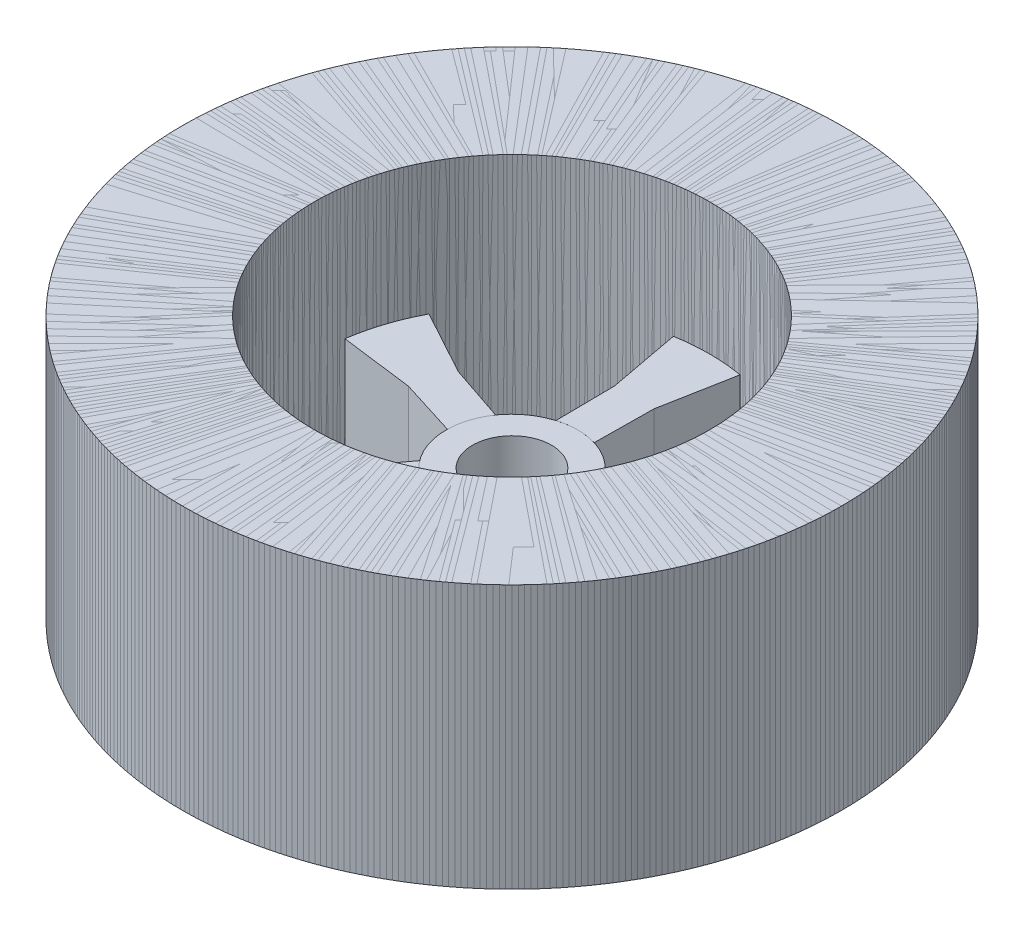
from build123d import *

# Parameters (mm, degrees)
SKETCH1_R           = 25
BOSS_EXTRUDE1_DEPTH = 20
BOSS_EXTRUDE3_DEPTH = 10
SKETCH1_3_R         = 3
BOSS_EXTRUDE2_DEPTH = 10
CIRPATTERN7_COUNT   = 5


with BuildPart() as part:
    # Sketch1 → Boss-Extrude1 (new body)
    with BuildSketch(Plane(origin=(0, 0, 0), x_dir=(1, 0, 0), z_dir=(0, 1, 0))):
        Circle(SKETCH1_R)
        with BuildLine():
            ThreePointArc((15, 0), (-9.670202954, -11.466785724), (-2.531623311, 14.784819357))
            ThreePointArc((-2.531623311, 14.784819357), (0, 15), (2.531623311, 14.784819357))
            ThreePointArc((2.531623311, 14.784819357), (11.466785724, 9.670202954), (15, 0))
        make_face(mode=Mode.SUBTRACT)
    extrude(amount=BOSS_EXTRUDE1_DEPTH)

    # Sketch1_4 → Boss-Extrude3 (add)
    with BuildSketch(Plane(origin=(0, 0, 0), x_dir=(1, 0, 0), z_dir=(0, 1, 0))):
        with BuildLine():
            ThreePointArc((2.531623311, 14.784819357), (0, 15), (-2.531623311, 14.784819357))
            Line((-2.531623311, 14.784819357), (-1.5, 9.284819357))
            Line((-1.5, 9.284819357), (-1.451035397, 4.784819357))
            ThreePointArc((-1.451035397, 4.784819357), (0, 5), (1.451035397, 4.784819357))
            Line((1.451035397, 4.784819357), (1.5, 9.284819357))
            Line((1.5, 9.284819357), (2.531623311, 14.784819357))
        make_face()
    extrude(amount=BOSS_EXTRUDE3_DEPTH)


with BuildPart() as body_2:
    # Sketch1_3 → Boss-Extrude2 (new body)
    with BuildSketch(Plane(origin=(0, 0, 0), x_dir=(1, 0, 0), z_dir=(0, 1, 0))):
        with BuildLine():
            ThreePointArc((1.451035397, 4.784819357), (0, 5), (-1.451035397, 4.784819357))
            ThreePointArc((-1.451035397, 4.784819357), (-2.978659347, -4.015916893), (5, 0))
            ThreePointArc((5, 0), (4.015916893, 2.978659347), (1.451035397, 4.784819357))
        make_face()
        Circle(SKETCH1_3_R, mode=Mode.SUBTRACT)
    extrude(amount=BOSS_EXTRUDE2_DEPTH)


with BuildPart() as cirpattern7_1:
    # CirPattern7: pattern copy
    add(part.part.rotate(Axis((0, 0, 0), (0, 1, 0)), 1 * 360 / CIRPATTERN7_COUNT))


with BuildPart() as cirpattern7_2:
    # CirPattern7: pattern copy
    add(part.part.rotate(Axis((0, 0, 0), (0, 1, 0)), 2 * 360 / CIRPATTERN7_COUNT))


with BuildPart() as cirpattern7_3:
    # CirPattern7: pattern copy
    add(part.part.rotate(Axis((0, 0, 0), (0, 1, 0)), 3 * 360 / CIRPATTERN7_COUNT))


with BuildPart() as cirpattern7_4:
    # CirPattern7: pattern copy
    add(part.part.rotate(Axis((0, 0, 0), (0, 1, 0)), 4 * 360 / CIRPATTERN7_COUNT))


solid = Compound([part.part, body_2.part, cirpattern7_1.part, cirpattern7_2.part, cirpattern7_3.part, cirpattern7_4.part])
